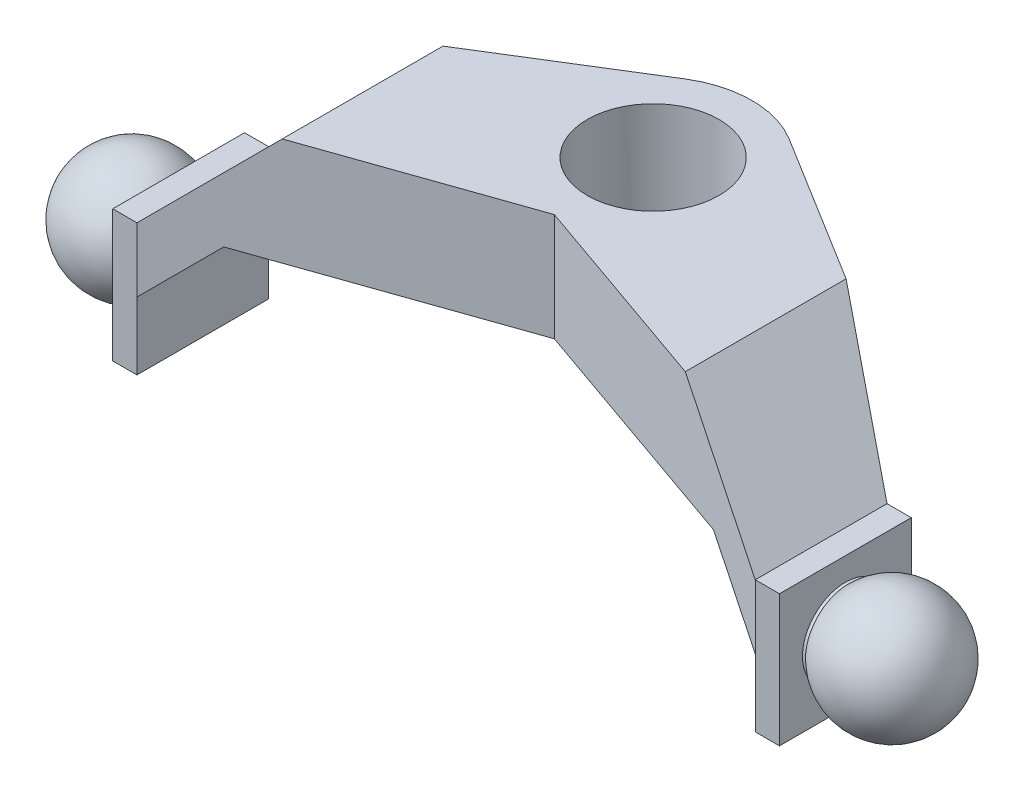
from build123d import *

# Parameters (mm, degrees)
SKETCH1_R                = 2.54
BOSS_EXTRUDE1_DEPTH      = 5.08
BOSS_EXTRUDE1_DEPTH_BACK = 5.08
CUT_EXTRUDE1_DEPTH       = 8.981097998
CUT_EXTRUDE1_DEPTH_BACK  = 4.81


with BuildPart() as part:
    # Sketch1 → Boss-Extrude1 (new body, two sides)
    with BuildSketch(Plane(origin=(0, 0, 0), x_dir=(1, 0, 0), z_dir=(0, 1, 0))) as boss_extrude1_sk:
        with BuildLine():
            Line((-2.006502941, 3.238834041), (-11.917388437, -2.901097998))
            Line((-11.917388437, -2.901097998), (-16.997388437, -2.901097998))
            Line((-16.997388437, -2.901097998), (-16.997388437, -7.981097998))
            Line((-16.997388437, -7.981097998), (-11.917388437, -7.981097998))
            Line((-11.917388437, -7.981097998), (0, -3.81))
            Line((0, -3.81), (11.917388437, -7.981097998))
            Line((11.917388437, -7.981097998), (16.997388437, -7.981097998))
            Line((16.997388437, -7.981097998), (16.997388437, -2.901097998))
            Line((16.997388437, -2.901097998), (11.917388437, -2.901097998))
            Line((11.917388437, -2.901097998), (2.006502941, 3.238834041))
            ThreePointArc((2.006502941, 3.238834041), (0, 3.81), (-2.006502941, 3.238834041))
        make_face()
        Circle(SKETCH1_R, mode=Mode.SUBTRACT)
    extrude(amount=BOSS_EXTRUDE1_DEPTH)
    extrude(boss_extrude1_sk.sketch, amount=-BOSS_EXTRUDE1_DEPTH_BACK)

    # Sketch2 → Cut-Extrude1 (cut, two sides)
    with BuildSketch(Plane.XY) as cut_extrude1_sk:
        Polygon((-11.917388437, -6.525255909), (-11.917388437, -2.478330742), (-9.439057695, 0), (9.439057695, 0), (11.917388437, -2.478330742), (11.917388437, -6.525255909), align=None)
        Polygon((-18.093487835, 0), (-11.917388437, 0), (-7.769454267, 4.147934171), (7.769454267, 4.147934171), (11.917388437, 0), (18.118549734, 0), (18.118549734, 7.57171578), (-18.093487835, 7.57171578), align=None)
    extrude(amount=CUT_EXTRUDE1_DEPTH, mode=Mode.SUBTRACT)
    extrude(cut_extrude1_sk.sketch, amount=-CUT_EXTRUDE1_DEPTH_BACK, mode=Mode.SUBTRACT)

    # Sketch3 → Cut-Revolve1 (revolve, cut)
    with BuildSketch(Plane.XY.offset(5.441097998)):
        with BuildLine():
            Line((-12.967633979, -0.885782562), (-12.851197898, -0.885782562))
            Line((-12.851197898, -0.885782562), (-12.851197898, 1.801061794))
            Line((-12.851197898, 1.801061794), (-18.158310447, 1.801061794))
            Line((-18.158310447, 1.801061794), (-18.158310447, -2.54))
            Line((-18.158310447, -2.54), (-16.997388437, -2.54))
            ThreePointArc((-16.997388437, -2.54), (-15.537067777, -0.361964398), (-12.967633979, -0.885782562))
        make_face()
        with BuildLine():
            Line((12.851197898, -0.885782562), (12.851197898, 1.801061794))
            Line((12.851197898, 1.801061794), (18.158310447, 1.801061794))
            Line((18.158310447, 1.801061794), (18.158310447, -2.54))
            Line((18.158310447, -2.54), (16.997388437, -2.54))
            ThreePointArc((16.997388437, -2.54), (15.537067777, -0.361964398), (12.967633979, -0.885782562))
            Line((12.967633979, -0.885782562), (12.851197898, -0.885782562))
        make_face()
    revolve(axis=Axis((-16.997388437, -2.54, 5.441097998), (1, 0, 0)), mode=Mode.SUBTRACT)


solid = part.part
